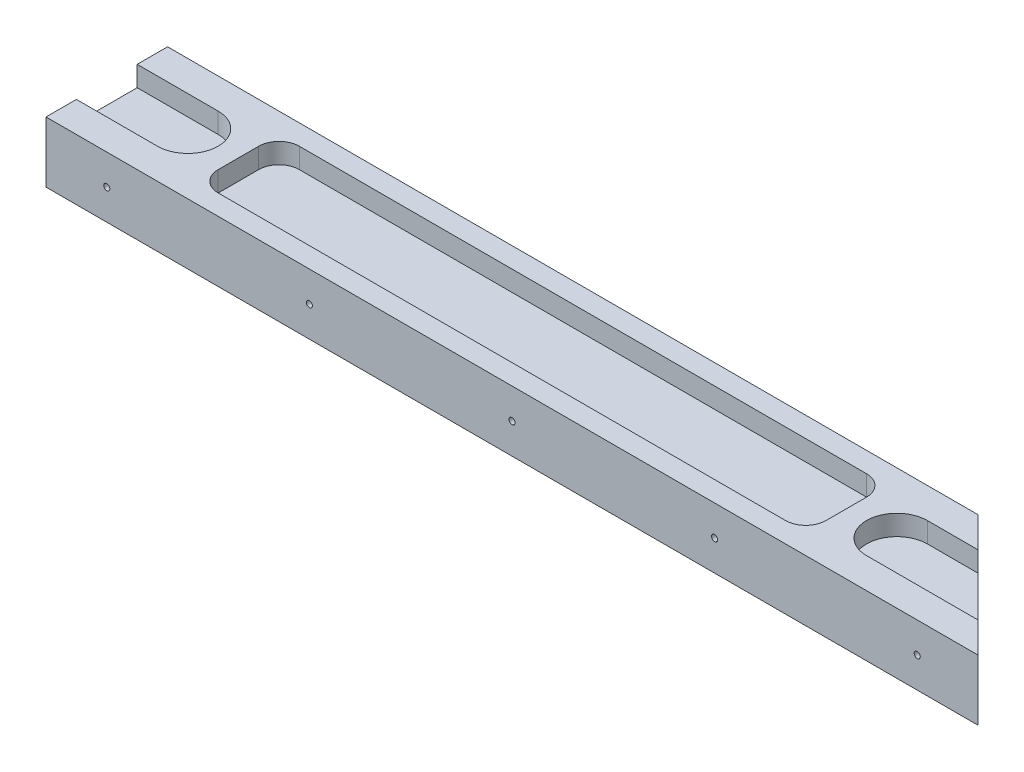
from build123d import *

# Parameters (mm, degrees)
BOSS_EXTRUDE1_DEPTH = 15
CUT_EXTRUDE1_DEPTH  = 5
CUT_EXTRUDE2_DEPTH  = 5
SKETCH4_R           = 0.75
CUT_EXTRUDE3_DEPTH  = 30
CUT_EXTRUDE4_DEPTH  = 5


with BuildPart() as part:
    # Sketch1 → Boss-Extrude1 (new body)
    with BuildSketch(Plane(origin=(0, 0, 0), x_dir=(1, 0, 0), z_dir=(0, 1, 0))):
        Polygon((0, 0), (230, 0), (200, 30), (0, 30), align=None)
    extrude(amount=BOSS_EXTRUDE1_DEPTH)

    # Sketch2 → Cut-Extrude1 (cut)
    with BuildSketch(Plane(origin=(0, 15, 0), x_dir=(1, 0, 0), z_dir=(0, 1, 0))):
        with BuildLine():
            Line((-20, 22.5), (20, 22.5))
            ThreePointArc((20, 22.5), (27.5, 15), (20, 7.5))
            Line((20, 7.5), (-20, 7.5))
            ThreePointArc((-20, 7.5), (-27.5, 15), (-20, 22.5))
        make_face()
        with BuildLine():
            Line((235, 22.5), (195, 22.5))
            ThreePointArc((195, 22.5), (187.5, 15), (195, 7.5))
            Line((195, 7.5), (235, 7.5))
            ThreePointArc((235, 7.5), (242.5, 15), (235, 22.5))
        make_face()
    extrude(amount=-CUT_EXTRUDE1_DEPTH, mode=Mode.SUBTRACT)

    # Sketch3 → Cut-Extrude2 (cut)
    with BuildSketch(Plane.XZ):
        with BuildLine():
            Line((195, -7.5), (222.5, -7.5))
            Line((222.5, -7.5), (207.5, -22.5))
            Line((207.5, -22.5), (195, -22.5))
            ThreePointArc((195, -22.5), (187.5, -15), (195, -7.5))
        make_face()
        with BuildLine():
            Line((0, -22.5), (0, -7.5))
            Line((0, -7.5), (20, -7.5))
            ThreePointArc((20, -7.5), (27.5, -15), (20, -22.5))
            Line((20, -22.5), (0, -22.5))
        make_face()
    extrude(amount=-CUT_EXTRUDE2_DEPTH, mode=Mode.SUBTRACT)

    # Sketch4 → Cut-Extrude3 (cut)
    with BuildSketch(Plane.XY):
        with Locations((115, 7.5)):
            Circle(SKETCH4_R)
        with Locations((165, 7.5)):
            Circle(SKETCH4_R)
        with Locations((215, 7.5)):
            Circle(SKETCH4_R)
        with Locations((65, 7.5)):
            Circle(SKETCH4_R)
        with Locations((15, 7.5)):
            Circle(SKETCH4_R)
    extrude(amount=-CUT_EXTRUDE3_DEPTH, mode=Mode.SUBTRACT)

    # Sketch5 → Cut-Extrude4 (cut)
    with BuildSketch(Plane(origin=(0, 15, 0), x_dir=(1, 0, 0), z_dir=(0, 1, 0))):
        with BuildLine():
            Line((37.5, 25), (177.5, 25))
            ThreePointArc((177.5, 25), (181.035533906, 23.535533906), (182.5, 20))
            Line((182.5, 20), (182.5, 10))
            ThreePointArc((182.5, 10), (181.035533906, 6.464466094), (177.5, 5))
            Line((177.5, 5), (37.5, 5))
            ThreePointArc((37.5, 5), (33.964466094, 6.464466094), (32.5, 10))
            Line((32.5, 10), (32.5, 20))
            ThreePointArc((32.5, 20), (33.964466094, 23.535533906), (37.5, 25))
        make_face()
    extrude(amount=-CUT_EXTRUDE4_DEPTH, mode=Mode.SUBTRACT)


solid = part.part
